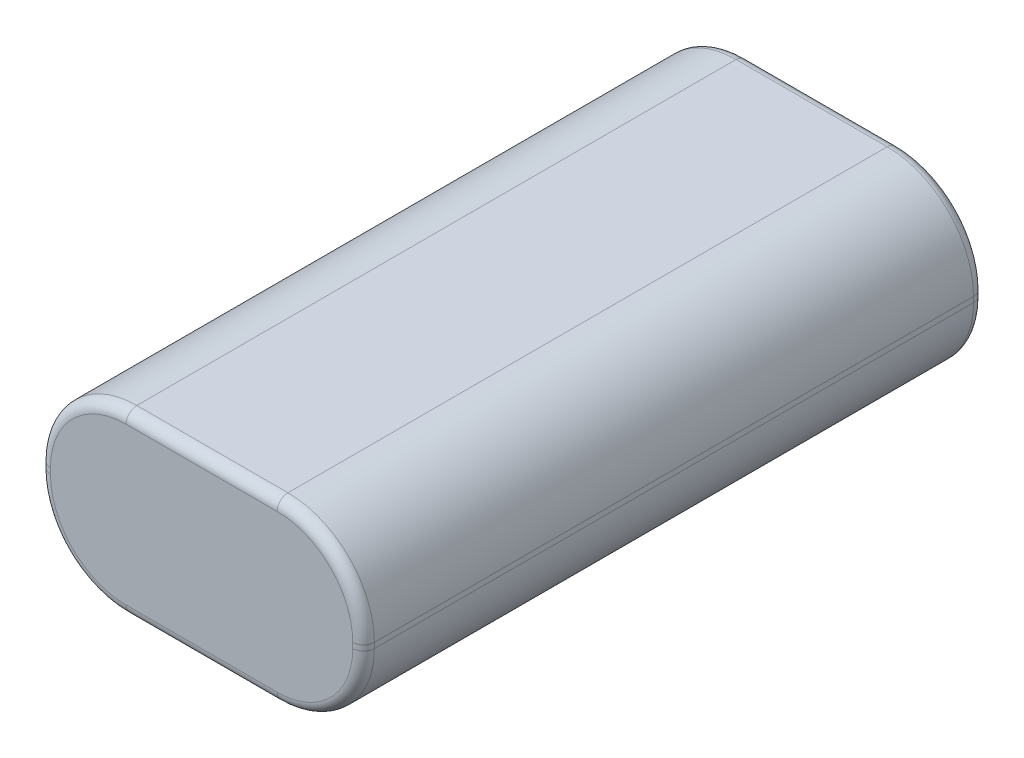
from build123d import *

# Parameters (mm, degrees)
BOSS_EXTRUDE1_DEPTH = 57.5
FILLET1_R           = 1


with BuildPart() as part:
    # Sketch1 → Boss-Extrude1 (new body)
    with BuildSketch(Plane.XY):
        with BuildLine():
            Line((8, 0), (22, 0))
            ThreePointArc((22, 0), (27.656854249, 2.343145751), (30, 8))
            Line((30, 8), (30, 8.5))
            ThreePointArc((30, 8.5), (27.656854249, 14.156854249), (22, 16.5))
            Line((22, 16.5), (8, 16.5))
            ThreePointArc((8, 16.5), (2.343145751, 14.156854249), (0, 8.5))
            Line((0, 8.5), (0, 8))
            ThreePointArc((0, 8), (2.343145751, 2.343145751), (8, 0))
        make_face()
    extrude(amount=BOSS_EXTRUDE1_DEPTH)

    # Fillet1
    fillet1_edges = [part.edges().sort_by_distance(p)[0] for p in [
        (27.656854249, 2.343145751, 57.5),
        (15, 0, 0),
        (2.343145751, 2.343145751, 0),
        (30, 8.25, 57.5),
        (27.656854249, 14.156854249, 57.5),
        (15, 16.5, 57.5),
        (2.343145751, 14.156854249, 57.5),
        (0, 8.25, 57.5),
        (2.343145751, 2.343145751, 57.5),
        (15, 0, 57.5),
        (0, 8.25, 0),
        (2.343145751, 14.156854249, 0),
        (15, 16.5, 0),
        (27.656854249, 14.156854249, 0),
        (30, 8.25, 0),
        (27.656854249, 2.343145751, 0),
    ]]
    fillet(fillet1_edges, radius=FILLET1_R)


solid = part.part
